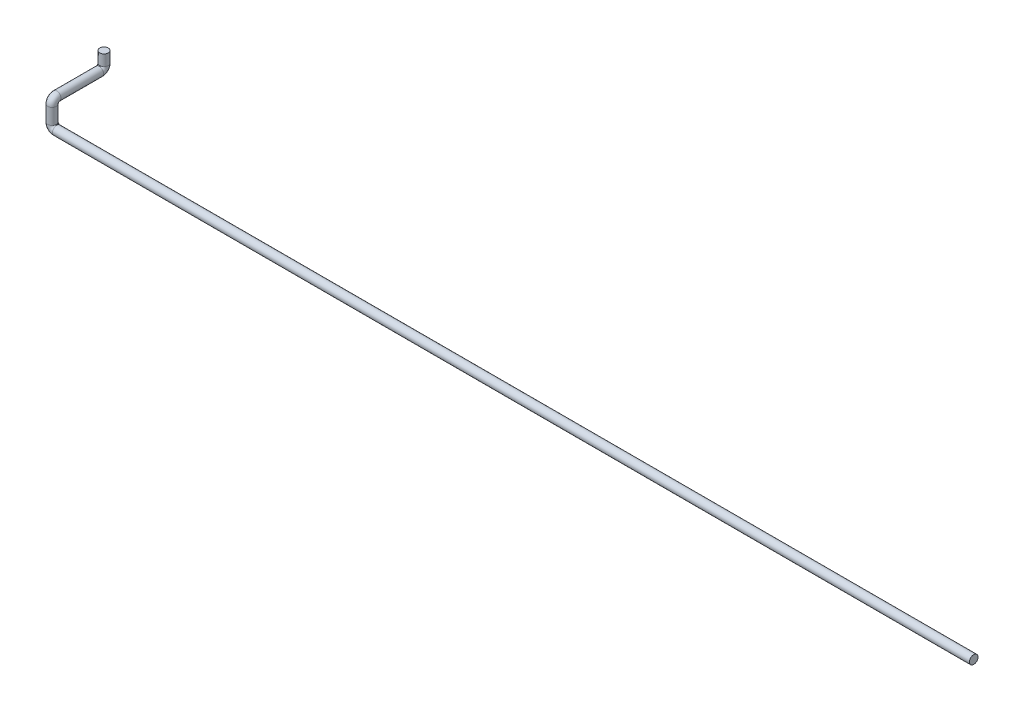
from build123d import *

# Parameters (mm, degrees)
CROQUIS1_R = 13.7


with BuildPart() as part:
    # Barrer1: sweep along a curve in space
    with BuildLine() as barrer1_path:
        Line((0, 0, 0), (-2930, 0, 0))
        ThreePointArc((-2930, 0, 0), (-2940.606601718, 4.393398282, 0), (-2945, 15, 0))
        Line((-2945, 15, 0), (-2945, 65, 0))
        ThreePointArc((-2945, 65, 0), (-2945, 75.606601718, -4.393398282), (-2945, 80, -15))
        Line((-2945, 80, -15), (-2945, 80, -151))
        ThreePointArc((-2945, 80, -151), (-2945, 84.393398282, -161.606601718), (-2945, 95, -166))
        Line((-2945, 95, -166), (-2945, 130, -166))
    # Croquis1 → Barrer1 (sweep)
    with BuildSketch(Plane(origin=(0, 0, 0), x_dir=(0, 0, -1), z_dir=(1, 0, 0))):
        Circle(CROQUIS1_R)
    sweep(path=barrer1_path.line)


solid = part.part
